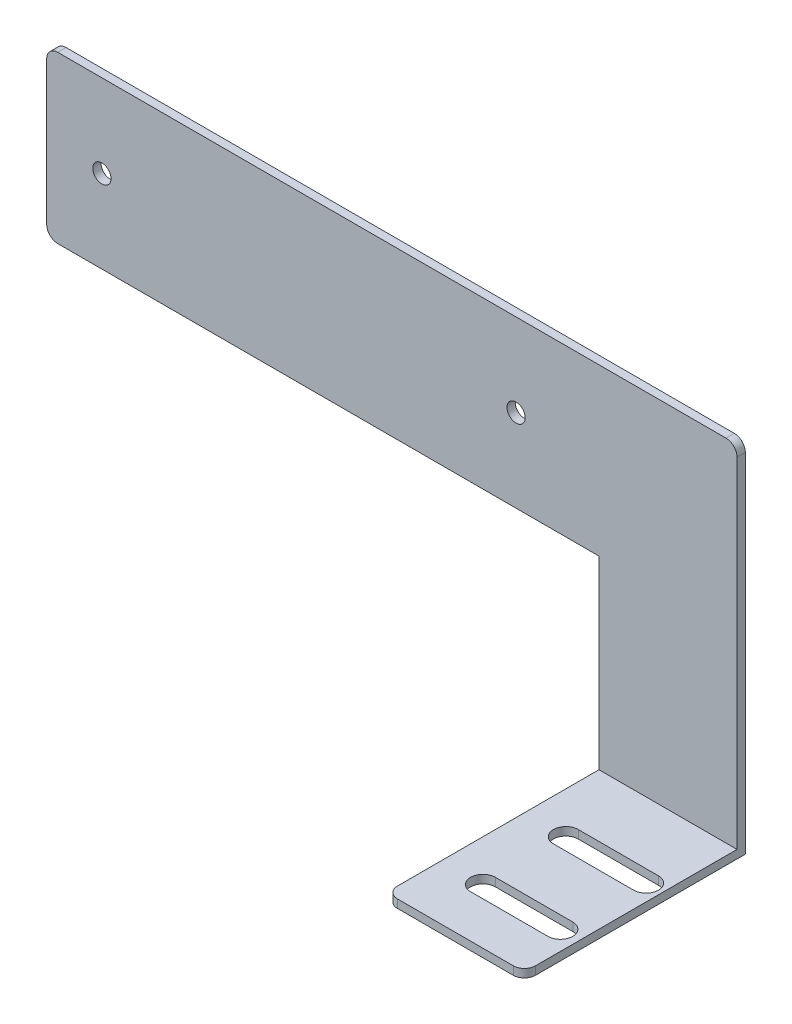
from build123d import *

# Parameters (mm, degrees)
BOSS_EXTRUDE1_DEPTH   = 1.5
SKETCH2_W             = 25
SKETCH2_H             = 1.5
BOSS_EXTRUDE2_DEPTH   = 38.5
FILLET1_R             = 2
CUT_EXTRUDE1_DEPTH    = 38.5
M4X0_7_TAPPED_HOLE1_D = 3.3


with BuildPart() as part:
    # Sketch1 → Boss-Extrude1 (new body)
    with BuildSketch(Plane.XY):
        Polygon((-54.090560102, -2.830140877), (70.909439898, -2.830140877), (70.909439898, -67.830140877), (45.909439898, -67.830140877), (45.909439898, -32.830140877), (-54.090560102, -32.830140877), align=None)
    extrude(amount=BOSS_EXTRUDE1_DEPTH)

    # Sketch2 → Boss-Extrude2 (add)
    with BuildSketch(Plane.XY.offset(1.5)):
        with Locations((58.409439898, -67.080140877)):
            Rectangle(SKETCH2_W, SKETCH2_H)
    extrude(amount=BOSS_EXTRUDE2_DEPTH)

    # Fillet1
    fillet1_edges = [part.edges().sort_by_distance(p)[0] for p in [
        (-54.090560102, -2.830140877, 0.75),
        (70.909439898, -2.830140877, 0.75),
        (-54.090560102, -32.830140877, 0.75),
        (45.909439898, -67.080140877, 40),
        (70.909439898, -67.080140877, 40),
    ]]
    fillet(fillet1_edges, radius=FILLET1_R)

    # Sketch3 → Cut-Extrude1 (cut)
    with BuildSketch(Plane.XZ.offset(67.830140877)):
        with BuildLine():
            Line((53.409439898, 32.25), (67.417341478, 32.25))
            ThreePointArc((67.417341478, 32.25), (69.667341478, 30), (67.417341478, 27.75))
            Line((67.417341478, 27.75), (53.409439898, 27.75))
            ThreePointArc((53.409439898, 27.75), (51.159439898, 30), (53.409439898, 32.25))
        make_face()
        with BuildLine():
            Line((67.936439633, 12.75), (53.409439898, 12.75))
            ThreePointArc((53.409439898, 12.75), (51.159439898, 15), (53.409439898, 17.25))
            Line((53.409439898, 17.25), (67.936439633, 17.25))
            ThreePointArc((67.936439633, 17.25), (70.186439633, 15), (67.936439633, 12.75))
        make_face()
    extrude(amount=-CUT_EXTRUDE1_DEPTH, mode=Mode.SUBTRACT)

    # M4x0.7 Tapped Hole1 (through all)
    with Locations(Plane.XY.offset(1.5)):
        with Locations((-44.090560102, -17.830140877), (30.909439898, -17.830140877)):
            Hole(M4X0_7_TAPPED_HOLE1_D / 2)


solid = part.part
